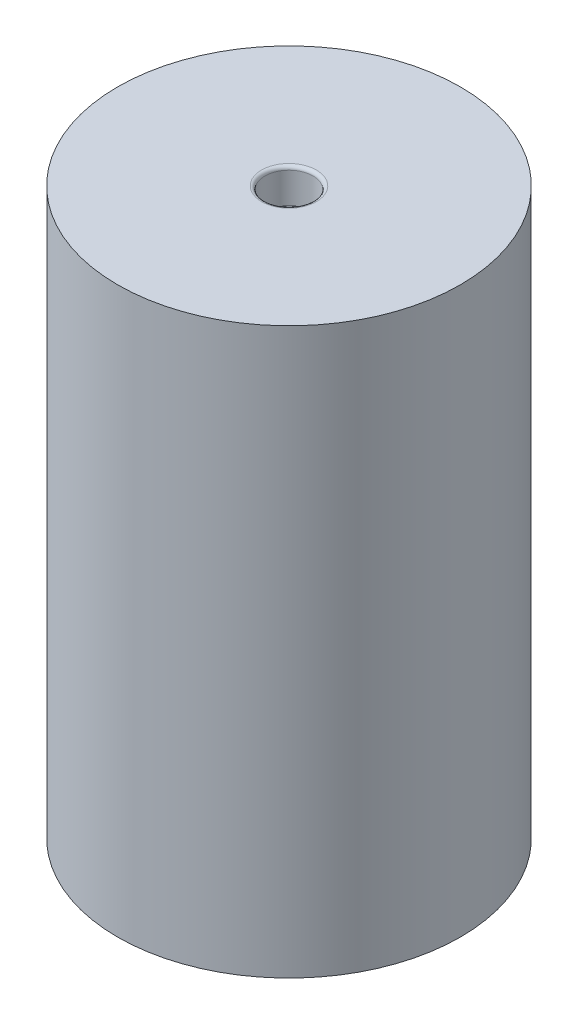
from build123d import *

# Parameters (mm, degrees)
SKETCH1_R           = 25
BOSS_EXTRUDE1_DEPTH = 82.4
SKETCH2_R           = 3.5
CUT_EXTRUDE1_DEPTH  = 5
SKETCH3_R           = 3.5
CUT_EXTRUDE2_DEPTH  = 5
FILLET1_R           = 0.5


with BuildPart() as part:
    # Sketch1 → Boss-Extrude1 (new body)
    with BuildSketch(Plane(origin=(0, 0, 0), x_dir=(1, 0, 0), z_dir=(0, 1, 0))):
        with Locations(Location((0, 0, 0), (0, 0, 270))):  # turned: the seam where the file's is
            Circle(SKETCH1_R)
    extrude(amount=BOSS_EXTRUDE1_DEPTH)

    # Sketch2 → Cut-Extrude1 (cut)
    with BuildSketch(Plane(origin=(0, 82.4, 0), x_dir=(1, 0, 0), z_dir=(0, 1, 0))):
        with Locations(Location((0, 0, 0), (0, 0, 270))):  # turned: the seam where the file's is
            Circle(SKETCH2_R)
    extrude(amount=-CUT_EXTRUDE1_DEPTH, mode=Mode.SUBTRACT)

    # Sketch3 → Cut-Extrude2 (cut)
    with BuildSketch(Plane.XZ):
        with Locations(Location((0, 0, 0), (0, 0, 90))):  # turned: the seam where the file's is
            Circle(SKETCH3_R)
    extrude(amount=-CUT_EXTRUDE2_DEPTH, mode=Mode.SUBTRACT)

    # Fillet1
    fillet1_edges = [part.edges().sort_by_distance(p)[0] for p in [
        (0, 0, -3.5),
        (0, 82.4, -3.5),
    ]]
    fillet(fillet1_edges, radius=FILLET1_R)


solid = part.part
